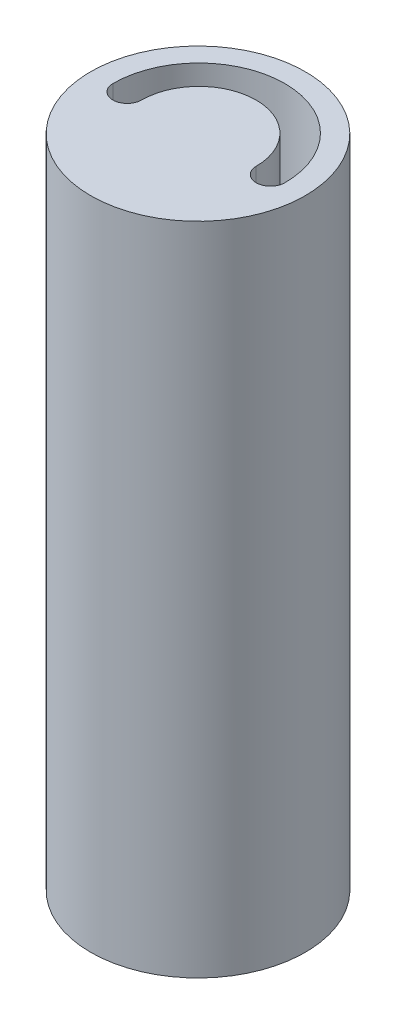
from build123d import *

# Parameters (mm, degrees)
SKETCH1_R           = 28.1
BOSS_EXTRUDE2_DEPTH = 61.3
SKETCH3_R           = 18.6
CUT_EXTRUDE2_DEPTH  = 58.8
SKETCH4_W           = 56.2
SKETCH4_H           = 56.2
BOSS_EXTRUDE3_DEPTH = 56.2
SKETCH5_R           = 16.1
CUT_EXTRUDE4_DEPTH  = 5
SKETCH6_W           = 49.797391422
SKETCH6_H           = 49.779255452
CUT_EXTRUDE5_DEPTH  = 53.7
SKETCH7_R           = 28.1
BOSS_EXTRUDE4_DEPTH = 321.5
CUT_EXTRUDE6_DEPTH  = 10
SKETCH9_R           = 3
CUT_EXTRUDE7_DEPTH  = 1
SKETCH10_R          = 6.025
CUT_EXTRUDE8_DEPTH  = 0.1
SKETCH18_R          = 3.75
CUT_EXTRUDE9_DEPTH  = 100
SKETCH19_R          = 3.75
CUT_EXTRUDE11_DEPTH = 325
SKETCH20_W          = 56.2
SKETCH20_H          = 56.2
CUT_EXTRUDE13_DEPTH = 200
SKETCH21_R          = 28.1
CUT_EXTRUDE14_DEPTH = 150


with BuildPart() as part:
    # Sketch1 → Boss-Extrude2 (new body)
    with BuildSketch(Plane.XY):
        Circle(SKETCH1_R)
    extrude(amount=BOSS_EXTRUDE2_DEPTH)

    # Sketch3 → Cut-Extrude2 (cut)
    with BuildSketch(Plane.XY.offset(61.3)):
        with Locations((0, -7)):
            Circle(SKETCH3_R)
    extrude(amount=-CUT_EXTRUDE2_DEPTH, mode=Mode.SUBTRACT)

    # Sketch4 → Boss-Extrude3 (add)
    with BuildSketch(Plane(origin=(0, 0, 0), x_dir=(-1, 0, 0), z_dir=(0, 0, -1))):
        Rectangle(SKETCH4_W, SKETCH4_H)
    extrude(amount=BOSS_EXTRUDE3_DEPTH)

    # Sketch5 → Cut-Extrude4 (cut)
    with BuildSketch(Plane.XY.offset(2.5)):
        with Locations((0, -7)):
            Circle(SKETCH5_R)
    extrude(amount=-CUT_EXTRUDE4_DEPTH, mode=Mode.SUBTRACT)

    # Sketch6 → Cut-Extrude5 (cut)
    with BuildSketch(Plane(origin=(0, 0, -56.2), x_dir=(-1, 0, 0), z_dir=(0, 0, -1))):
        Rectangle(SKETCH6_W, SKETCH6_H)
    extrude(amount=-CUT_EXTRUDE5_DEPTH, mode=Mode.SUBTRACT)

    # Sketch7 → Boss-Extrude4 (add)
    with BuildSketch(Plane(origin=(0, -28.1, 0), x_dir=(-1, 0, 0), z_dir=(0, -1, 0))):
        with Locations(Location((0, 28.1, 0), (0, 0, 90))):
            Circle(SKETCH7_R)
    extrude(amount=BOSS_EXTRUDE4_DEPTH)

    # Sketch8 → Cut-Extrude6 (cut)
    with BuildSketch(Plane(origin=(0, -349.6, 0), x_dir=(-1, 0, 0), z_dir=(0, -1, 0))):
        with BuildLine():
            Line((-1.658312395, 25.832078896), (1.658312395, 25.832078896))
            ThreePointArc((1.658312395, 25.832078896), (3, 28.332078896), (1.658312395, 30.832078896))
            Line((1.658312395, 30.832078896), (-1.658312395, 30.832078896))
            ThreePointArc((-1.658312395, 30.832078896), (-3, 28.332078896), (-1.658312395, 25.832078896))
        make_face()
    extrude(amount=-CUT_EXTRUDE6_DEPTH, mode=Mode.SUBTRACT)

    # Sketch9 → Cut-Extrude7 (cut)
    with BuildSketch(Plane(origin=(0, -349.6, 0), x_dir=(-1, 0, 0), z_dir=(0, -1, 0))):
        with Locations(Location((0, 28.332078896, 0), (0, 0, 90))):
            Circle(SKETCH9_R)
    extrude(amount=-CUT_EXTRUDE7_DEPTH, mode=Mode.SUBTRACT)

    # Sketch10 → Cut-Extrude8 (cut)
    with BuildSketch(Plane(origin=(0, -349.6, 0), x_dir=(-1, 0, 0), z_dir=(0, -1, 0))):
        with Locations(Location((0, 28.332078896, 0), (0, 0, 90))):
            Circle(SKETCH10_R)
    extrude(amount=-CUT_EXTRUDE8_DEPTH, mode=Mode.SUBTRACT)

    # Cut-Sweep4: sweep along a path in Sketch15
    with BuildLine(Plane(origin=(0, -349.6, 0), x_dir=(-1, 0, 0), z_dir=(0, -1, 0))) as cut_sweep4_path:
        ThreePointArc((15, 28.332078896), (0, 43.332078896), (-15, 28.332078896))
    # 3DSketch2 → Cut-Sweep4 (sweep, cut)
    with BuildSketch(Plane(origin=(-15, -349.6, -28.332078896), x_dir=(-0.022748965612757834, 0.999741208795331, 0), z_dir=(0, 0, 1))):
        Polygon((0, 0), (0.170617242, 7.498059066), (329.685319661, 0), (329.514702419, -7.498059066), align=None)
    sweep(path=cut_sweep4_path.line, mode=Mode.SUBTRACT)

    # Sketch18 → Cut-Extrude9 (cut)
    with BuildSketch(Plane.XY.offset(61.3)):
        with Locations((0, 18.75)):
            Circle(SKETCH18_R)
    extrude(amount=-CUT_EXTRUDE9_DEPTH, mode=Mode.SUBTRACT)

    # Sketch19 → Cut-Extrude11 (cut)
    with BuildSketch(Plane(origin=(0, -349.6, 0), x_dir=(-1, 0, 0), z_dir=(0, -1, 0))):
        with Locations((-18.75, 28.332078896)):
            Circle(SKETCH19_R)
        with Locations((18.75, 28.332078896)):
            Circle(SKETCH19_R)
    extrude(amount=-CUT_EXTRUDE11_DEPTH, mode=Mode.SUBTRACT)

    # Sketch20 → Cut-Extrude13 (cut)
    with BuildSketch(Plane(origin=(0, 0, -56.2), x_dir=(-1, 0, 0), z_dir=(0, 0, -1))):
        Rectangle(SKETCH20_W, SKETCH20_H)
    extrude(amount=-CUT_EXTRUDE13_DEPTH, mode=Mode.SUBTRACT)

    # Sketch21 → Cut-Extrude14 (cut)
    with BuildSketch(Plane(origin=(0, -28.1, 0), x_dir=(1, 0, 0), z_dir=(0, 1, 0))):
        with Locations(Location((0, 28.1, 0), (0, 0, 270))):
            Circle(SKETCH21_R)
    extrude(amount=-CUT_EXTRUDE14_DEPTH, mode=Mode.SUBTRACT)


solid = part.part
